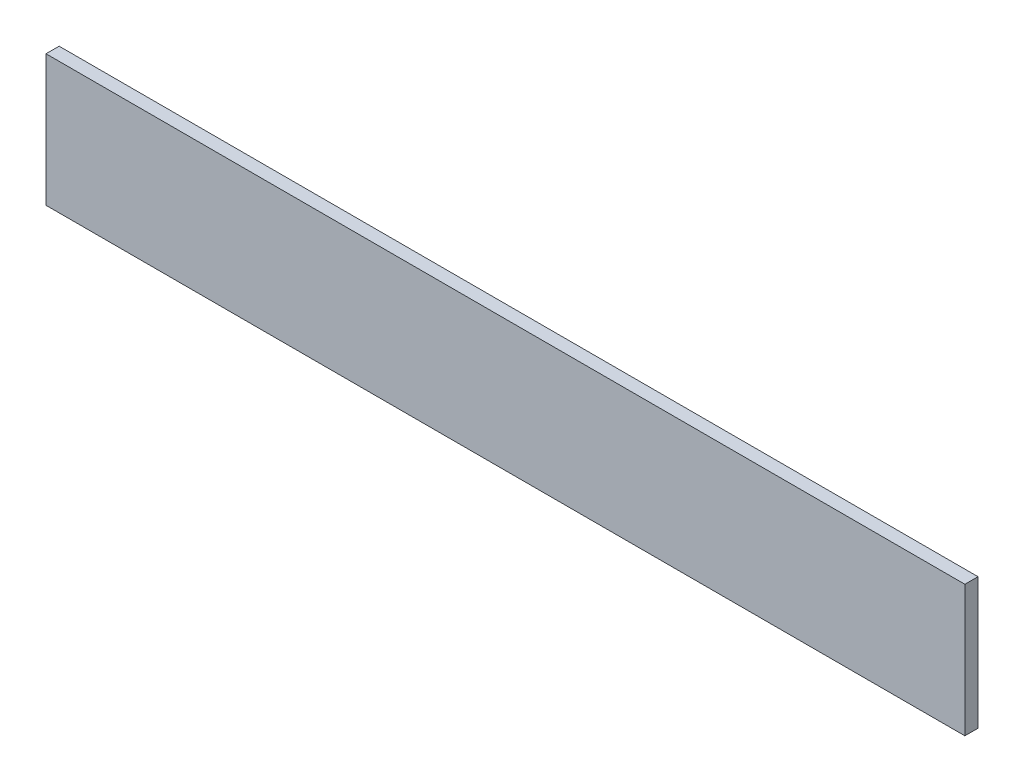
from build123d import *

# Parameters (mm, degrees)
SKETCH_1_W      = 140
SKETCH_1_H      = 20
EXTRUDE_1_DEPTH = 2


with BuildPart() as part:
    # Эскиз1 → Бобышка-Вытянуть1 (new body)
    with BuildSketch(Plane.XY):
        with Locations((70, -10)):
            Rectangle(SKETCH_1_W, SKETCH_1_H)
    extrude(amount=EXTRUDE_1_DEPTH)


solid = part.part
